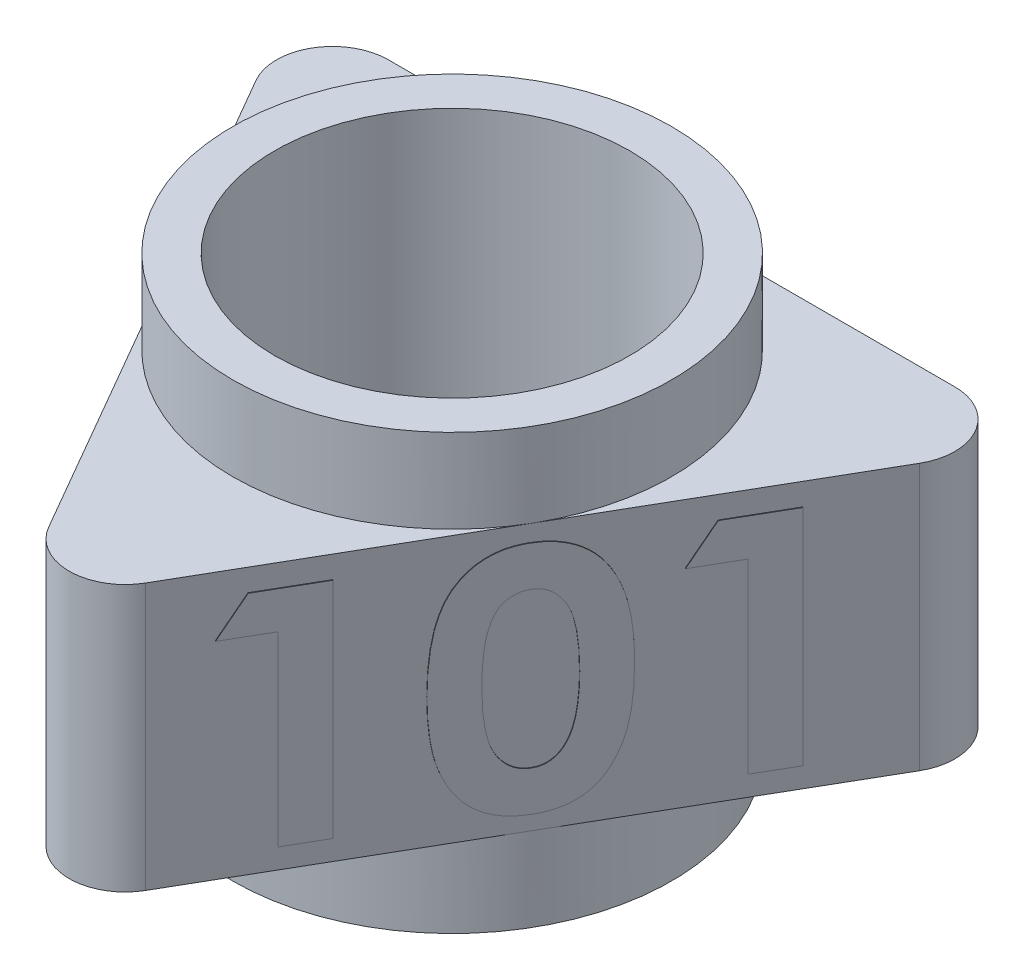
from build123d import *

# Parameters (mm, degrees)
SKETCH1_R                = 6.35
BOSS_EXTRUDE1_DEPTH      = 4.7625
FILLET1_R                = 2
BOSS_EXTRUDE2_DEPTH      = 0.0254
CIRPATTERN1_COUNT        = 3
SKETCH3_R                = 7.85
SKETCH3_R_2              = 6.35
BOSS_EXTRUDE3_DEPTH      = 3
BOSS_EXTRUDE3_DEPTH_BACK = 12.525


with BuildPart() as part:
    # Sketch1 → Boss-Extrude1 (new body, symmetric)
    with BuildSketch(Plane(origin=(0, 0, 0), x_dir=(1, 0, 0), z_dir=(0, 1, 0))):
        Polygon((0, -15.7), (13.596598839, 7.85), (-13.596598839, 7.85), align=None)
        with Locations(Location((0, 0, 0), (0, 0, 270))):  # turned: the seam where the file's is
            Circle(SKETCH1_R, mode=Mode.SUBTRACT)
    extrude(amount=BOSS_EXTRUDE1_DEPTH, both=True)

    # Fillet1
    fillet1_edges = [part.edges().sort_by_distance(p)[0] for p in [
        (-13.596598839, 0, -7.85),
        (13.596598839, 0, -7.85),
        (0, 0, 15.7),
    ]]
    fillet(fillet1_edges, radius=FILLET1_R)

    # Sketch2 → Boss-Extrude2 (add)
    with BuildSketch(Plane(origin=(6.79829942, 0, 3.925), x_dir=(0.5, 0, -0.866025404), z_dir=(0.866025404, 0, 0.5))):
        Polygon((-7.450320513, 3.969511638), (-5.230769231, 3.969511638), (-5.230769231, -4.030488362), (-6.666666667, -4.030488362), (-6.666666667, 2.636178305), (-8.307692308, 2.636178305), align=None)
        with BuildLine():
            add(Edge.make_bspline(
                [(-0.075320513, 4.174639843), (-0.005817117, 4.173608045), (0.130845128, 4.171579256), (0.332122892, 4.149605813), (0.526009028, 4.116410068), (0.713262042, 4.070113579), (0.892534071, 4.008841826), (1.06512989, 3.935500588), (1.228995112, 3.846242965), (1.386219542, 3.745421896), (1.536742616, 3.631278153), (1.676946617, 3.501148393), (1.809391969, 3.358026907), (1.931211717, 3.199749954), (2.045103597, 3.027757231), (2.150693379, 2.842021465), (2.247172747, 2.641633606), (2.335623005, 2.426232036), (2.414715506, 2.192587979), (2.481335021, 1.938021436), (2.538472402, 1.662474273), (2.586700384, 1.365260612), (2.623152943, 1.045985383), (2.647722701, 0.704860699), (2.664583633, 0.342544196), (2.665959705, 0.093998052), (2.666666667, -0.03369349)],
                knots=[0, 0, 0, 0, 0.879237366, 1.728815576, 2.559023295, 3.367336655, 4.166867292, 4.954216142, 5.737608147, 6.525189134, 7.316157332, 8.124696809, 8.942788509, 9.781158001, 10.649253743, 11.551476218, 12.482711956, 13.461909668, 14.496590415, 15.601789533, 16.789733467, 18.056700938, 19.410929216, 20.8549011, 22.384193279, 24, 24, 24, 24], degree=3))
            add(Edge.make_bspline(
                [(2.666666667, -0.03369349), (2.665902632, -0.162982598), (2.664418125, -0.414189014), (2.648423615, -0.779819447), (2.620880313, -1.123420902), (2.585380518, -1.44495783), (2.53675551, -1.744260432), (2.479808865, -2.022103702), (2.412137781, -2.278386928), (2.330439999, -2.512532649), (2.242525133, -2.728312511), (2.145781852, -2.928309662), (2.041896378, -3.113065805), (1.933251532, -3.285368237), (1.813891003, -3.44013757), (1.689624405, -3.582636771), (1.555040948, -3.707437863), (1.415807115, -3.820972533), (1.266822209, -3.919089273), (1.109622672, -4.004900555), (0.941405908, -4.074503697), (0.765238224, -4.135040792), (0.578116805, -4.178499895), (0.383014985, -4.212983264), (0.177730103, -4.232040889), (0.037963888, -4.234405113), (-0.033653846, -4.235616567)],
                knots=[0, 0, 0, 0, 1.643780988, 3.193836972, 4.651895693, 6.025988579, 7.305620092, 8.505800249, 9.631074763, 10.672816429, 11.65661981, 12.592235626, 13.49536222, 14.350718032, 15.179365177, 15.97804903, 16.751647189, 17.51006938, 18.259804725, 19.016521909, 19.783502495, 20.571750527, 21.382245291, 22.22305063, 23.089471752, 24, 24, 24, 24], degree=3))
            add(Edge.make_bspline(
                [(-0.033653846, -4.235616567), (-0.105269647, -4.234381745), (-0.245563948, -4.231962746), (-0.45140394, -4.213124966), (-0.647539702, -4.178360202), (-0.836141552, -4.134707145), (-1.015896852, -4.074637641), (-1.187667522, -4.002952023), (-1.350132795, -3.91767616), (-1.503742511, -3.819330818), (-1.647972204, -3.706555781), (-1.785063202, -3.580557304), (-1.914712251, -3.44165476), (-2.034947068, -3.288292327), (-2.147736752, -3.122517074), (-2.251905084, -2.942435926), (-2.347389463, -2.748311079), (-2.437176656, -2.539871942), (-2.515190361, -2.312631059), (-2.584618937, -2.064559198), (-2.641493, -1.793588477), (-2.687234927, -1.499805946), (-2.723755256, -1.183833997), (-2.750922182, -0.845520119), (-2.767005534, -0.484706735), (-2.768474473, -0.236701723), (-2.769230769, -0.109014003)],
                knots=[0, 0, 0, 0, 0.917216111, 1.796812873, 2.643793957, 3.46689424, 4.273913431, 5.068098542, 5.848489301, 6.620921603, 7.401012384, 8.190319798, 9.003608147, 9.831726257, 10.68377682, 11.569763213, 12.493818149, 13.453288342, 14.474581811, 15.568529029, 16.750744269, 18.018426408, 19.375425659, 20.823733699, 22.36466933, 24, 24, 24, 24], degree=3))
            add(Edge.make_bspline(
                [(-2.769230769, -0.109014003), (-2.767860808, 0.068398032), (-2.765217452, 0.410716839), (-2.731718891, 0.905267985), (-2.6825515, 1.362394852), (-2.610336249, 1.781332777), (-2.52104309, 2.163633386), (-2.406698551, 2.506778281), (-2.276525611, 2.815515642), (-2.165601543, 2.998413514), (-2.112179487, 3.086498817)],
                knots=[0, 0, 0, 0, 1.288568992, 2.486310467, 3.599230591, 4.627010532, 5.572937695, 6.447898582, 7.252493626, 8, 8, 8, 8], degree=3))
            add(Edge.make_bspline(
                [(-2.112179487, 3.086498817), (-2.050062866, 3.173033792), (-1.92861263, 3.342226719), (-1.716253499, 3.564345407), (-1.488101262, 3.754312185), (-1.239469801, 3.907827935), (-0.974291327, 4.028890469), (-0.690289148, 4.114395572), (-0.388512035, 4.16421483), (-0.181276659, 4.171112946), (-0.075320513, 4.174639843)],
                knots=[0, 0, 0, 0, 1.058512271, 2.069600068, 3.047294572, 4.004278952, 4.967380941, 5.939006123, 6.946246673, 8, 8, 8, 8], degree=3))
        make_face()
        with BuildLine():
            add(Edge.make_bspline(
                [(-0.040064103, 2.738742407), (-0.102895749, 2.735764312), (-0.226079128, 2.729925665), (-0.40482408, 2.680363787), (-0.57336941, 2.603812794), (-0.70157734, 2.511695644), (-0.797539702, 2.423390308), (-0.864589291, 2.343476851), (-0.929248053, 2.254299192), (-0.986357927, 2.151833203), (-1.040284556, 2.039760607), (-1.092987128, 1.917572661), (-1.136189397, 1.782268166), (-1.178634482, 1.636151375), (-1.215820336, 1.475182546), (-1.24697393, 1.298045937), (-1.274806928, 1.103589612), (-1.294220776, 0.891686203), (-1.312320308, 0.662557411), (-1.32529491, 0.415692828), (-1.330719265, 0.151159052), (-1.332443503, -0.031021434), (-1.333333333, -0.125039644)],
                knots=[0, 0, 0, 0, 1.076674018, 2.110852608, 3.161083442, 4.239746716, 4.804137807, 5.395870207, 6.026861976, 6.692161227, 7.405688833, 8.16177676, 8.973626916, 9.841385931, 10.773283133, 11.807421078, 12.927755683, 14.143907515, 15.458935494, 16.872852025, 18.386167141, 20, 20, 20, 20], degree=3))
            add(Edge.make_bspline(
                [(-1.333333333, -0.125039644), (-1.331868781, -0.24684478), (-1.329060392, -0.480415159), (-1.314351365, -0.816297497), (-1.284868342, -1.121977471), (-1.248197414, -1.399526787), (-1.196691599, -1.647145463), (-1.137430823, -1.867176202), (-1.064249035, -2.056814145), (-0.979673378, -2.218801885), (-0.886002027, -2.356604519), (-0.784317655, -2.473737379), (-0.678082251, -2.575168909), (-0.563979861, -2.65756049), (-0.4422827, -2.720701601), (-0.314006717, -2.766118222), (-0.179070392, -2.793919627), (-0.086667387, -2.797774788), (-0.040064103, -2.799719131)],
                knots=[0, 0, 0, 0, 1.771748488, 3.397459088, 4.888034009, 6.237357457, 7.467047327, 8.564189669, 9.548206622, 10.417051504, 11.216568818, 11.965764335, 12.669334354, 13.348544111, 14.005342236, 14.656555988, 15.322436492, 16, 16, 16, 16], degree=3))
            add(Edge.make_bspline(
                [(-0.040064103, -2.799719131), (0.004939905, -2.798388667), (0.093052156, -2.795783784), (0.221539552, -2.769045005), (0.343046363, -2.725573558), (0.457205723, -2.664080145), (0.564425963, -2.585881861), (0.664183058, -2.49063507), (0.755724659, -2.377390383), (0.809057211, -2.293346078), (0.836538462, -2.250039644)],
                knots=[0, 0, 0, 0, 0.992283464, 1.942767638, 2.88273346, 3.832339453, 4.79467288, 5.803907806, 6.868395428, 8, 8, 8, 8], degree=3))
            add(Edge.make_bspline(
                [(0.836538462, -2.250039644), (0.868893006, -2.190862787), (0.936737861, -2.066773716), (1.015248045, -1.857378036), (1.081333542, -1.621214318), (1.138212363, -1.357547597), (1.177114007, -1.065337939), (1.210616055, -0.746438271), (1.226774926, -0.399242744), (1.229403254, -0.15870443), (1.230769231, -0.03369349)],
                knots=[0, 0, 0, 0, 0.710965849, 1.490837728, 2.352621235, 3.297892224, 4.334225155, 5.461620853, 6.680770821, 8, 8, 8, 8], degree=3))
            add(Edge.make_bspline(
                [(1.230769231, -0.03369349), (1.230241583, 0.092402605), (1.229225952, 0.335116062), (1.210592062, 0.683559781), (1.184642946, 1.00180529), (1.146686881, 1.289142075), (1.097849504, 1.546267663), (1.037657253, 1.773165247), (0.966695066, 1.970281998), (0.882542369, 2.137421363), (0.789338029, 2.279466896), (0.690398776, 2.401330945), (0.585306256, 2.505375396), (0.474236218, 2.591991785), (0.354617905, 2.658173203), (0.228736185, 2.704902759), (0.09633299, 2.733172573), (0.006015267, 2.736860736), (-0.040064103, 2.738742407)],
                knots=[0, 0, 0, 0, 1.793836731, 3.452829483, 4.963243077, 6.335886805, 7.574563692, 8.684454726, 9.672768357, 10.54971625, 11.340229787, 12.085688095, 12.778991901, 13.440269426, 14.083255152, 14.715733572, 15.344777694, 16, 16, 16, 16], degree=3))
        make_face(mode=Mode.SUBTRACT)
        Polygon((4.857371795, 3.969511638), (7.076923077, 3.969511638), (7.076923077, -4.030488362), (5.641025641, -4.030488362), (5.641025641, 2.636178305), (4, 2.636178305), align=None)
    boss_extrude2 = extrude(amount=BOSS_EXTRUDE2_DEPTH)

    # CirPattern1: Boss-Extrude2 ×3 about axis
    cirpattern1_axis = Axis((0, 5.23875, 0), (0, -1, 0))
    for i in range(1, CIRPATTERN1_COUNT):
        add(boss_extrude2.rotate(cirpattern1_axis, i * 360 / CIRPATTERN1_COUNT))

    # Sketch3 → Boss-Extrude3 (add, two sides)
    with BuildSketch(Plane(origin=(0, 4.7625, 0), x_dir=(1, 0, 0), z_dir=(0, 1, 0))) as boss_extrude3_sk:
        with Locations(Location((0, 0, 0), (0, 0, 270))):  # turned: the seam where the file's is
            Circle(SKETCH3_R)
        with Locations(Location((0, 0, 0), (0, 0, 270))):  # turned: the seam where the file's is
            Circle(SKETCH3_R_2, mode=Mode.SUBTRACT)
    extrude(amount=BOSS_EXTRUDE3_DEPTH)
    extrude(boss_extrude3_sk.sketch, amount=-BOSS_EXTRUDE3_DEPTH_BACK)


solid = part.part
